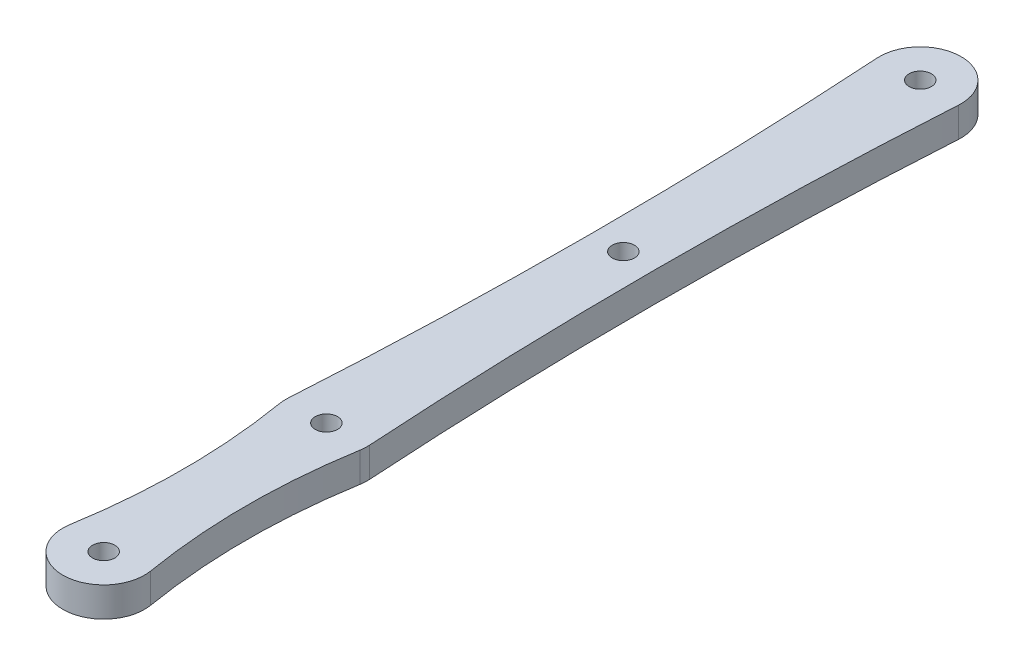
from build123d import *

# Parameters (mm, degrees)
SKETCH1_R           = 1.5
BOSS_EXTRUDE1_DEPTH = 4


with BuildPart() as part:
    # Sketch1 → Boss-Extrude1 (new body)
    with BuildSketch(Plane(origin=(0, 0, 0), x_dir=(1, 0, 0), z_dir=(0, 1, 0))):
        with BuildLine():
            ThreePointArc((-5.424137931, 0.910344828), (0, -5.5), (5.424137931, 0.910344828))
            ThreePointArc((5.424137931, 0.910344828), (4.25, 15), (5.424137931, 29.089655172))
            ThreePointArc((5.424137931, 29.089655172), (5.492593836, 29.71467045), (5.489268293, 30.343414634))
            ThreePointArc((5.489268293, 30.343414634), (4.25, 70), (5.489268293, 109.656585366))
            ThreePointArc((5.489268293, 109.656585366), (0, 115.5), (-5.489268293, 109.656585366))
            ThreePointArc((-5.489268293, 109.656585366), (-4.25, 70), (-5.489268293, 30.343414634))
            ThreePointArc((-5.489268293, 30.343414634), (-5.492593836, 29.71467045), (-5.424137931, 29.089655172))
            ThreePointArc((-5.424137931, 29.089655172), (-4.25, 15), (-5.424137931, 0.910344828))
        make_face()
        Circle(SKETCH1_R, mode=Mode.SUBTRACT)
        with Locations((0, 110)):
            Circle(SKETCH1_R, mode=Mode.SUBTRACT)
        with Locations((0, 30)):
            Circle(SKETCH1_R, mode=Mode.SUBTRACT)
        with Locations((0, 70)):
            Circle(SKETCH1_R, mode=Mode.SUBTRACT)
    extrude(amount=BOSS_EXTRUDE1_DEPTH)


solid = part.part
